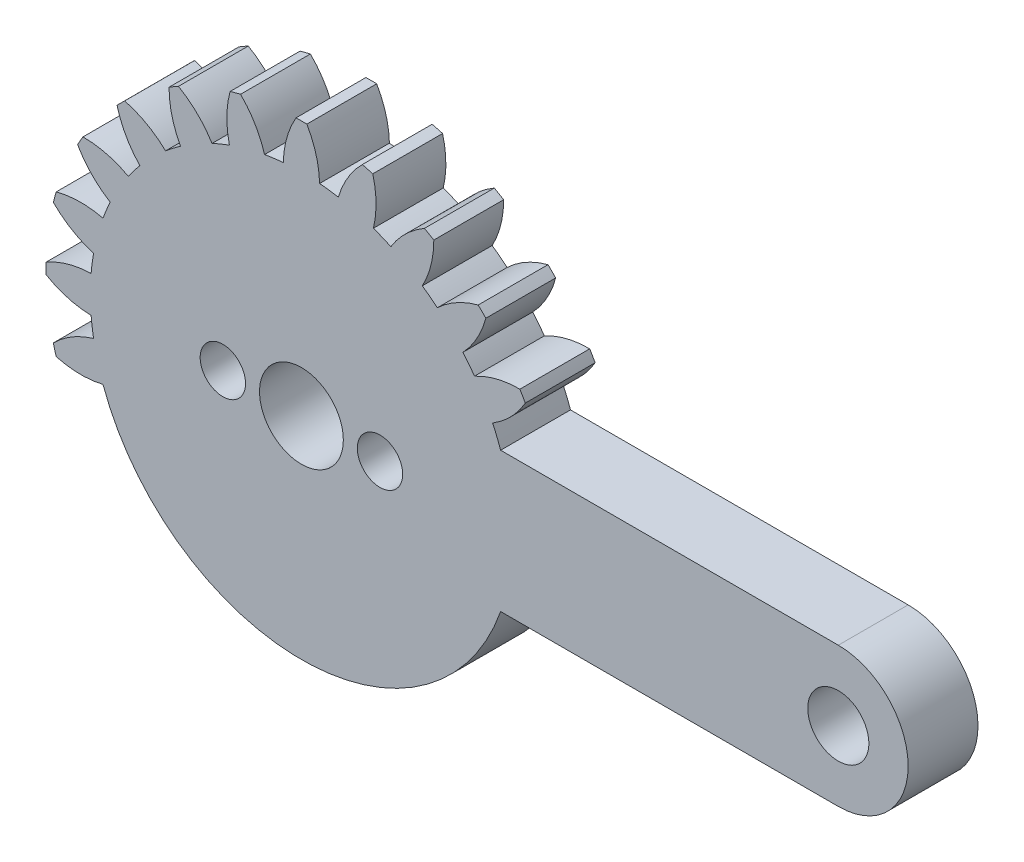
from build123d import *

# Parameters (mm, degrees)
ESQUISSE1_R                  = 1.75
BOSS_EXTRU_1_DEPTH           = 2
ESQUISSE2_R                  = 1.3
ESQUISSE2_R_2                = 2.4
ENL_V_MAT_EXTRU_1_DEPTH      = 1
ENL_V_MAT_EXTRU_1_DEPTH_BACK = 5


with BuildPart() as part:
    # Esquisse1 → Boss.-Extru.1 (new body, symmetric)
    with BuildSketch(Plane.XY):
        with BuildLine():
            ThreePointArc((30.75, -4), (34.75, 0), (30.75, 4))
            Line((30.75, 4), (11.409123542, 4))
            ThreePointArc((11.409123542, 4), (11.194344337, 4.566700654), (10.951436862, 5.12192646))
            ThreePointArc((10.951436862, 5.12192646), (12.008090957, 5.965388247), (12.82210701, 7.044889767))
            ThreePointArc((12.82210701, 7.044889767), (12.669951657, 7.315), (12.51210701, 7.581825517))
            ThreePointArc((12.51210701, 7.581825517), (11.170223244, 7.416617696), (9.911436862, 6.9232593))
            ThreePointArc((9.911436862, 6.9232593), (9.591641884, 7.359925677), (9.252623584, 7.781841479))
            ThreePointArc((9.252623584, 7.781841479), (10.05496909, 8.870045207), (10.561852666, 10.123446462))
            ThreePointArc((10.561852666, 10.123446462), (10.344972209, 10.344972209), (10.123446462, 10.561852666))
            ThreePointArc((10.123446462, 10.561852666), (8.870045207, 10.05496909), (7.781841479, 9.252623584))
            ThreePointArc((7.781841479, 9.252623584), (7.359925677, 9.591641884), (6.9232593, 9.911436862))
            ThreePointArc((6.9232593, 9.911436862), (7.416617696, 11.170223244), (7.581825517, 12.51210701))
            ThreePointArc((7.581825517, 12.51210701), (7.315, 12.669951657), (7.044889767, 12.82210701))
            ThreePointArc((7.044889767, 12.82210701), (5.965388247, 12.008090957), (5.12192646, 10.951436862))
            ThreePointArc((5.12192646, 10.951436862), (4.626642697, 11.169703548), (4.122086336, 11.365584201))
            ThreePointArc((4.122086336, 11.365584201), (4.272836063, 12.709169027), (4.085109489, 14.048088143))
            ThreePointArc((4.085109489, 14.048088143), (3.78652263, 14.131494839), (3.486235477, 14.208555951))
            ThreePointArc((3.486235477, 14.208555951), (2.654199937, 13.14288127), (2.112960617, 11.903927815))
            ThreePointArc((2.112960617, 11.903927815), (1.578061664, 11.986568374), (1.04, 12.04518576))
            ThreePointArc((1.04, 12.04518576), (0.837867713, 13.382005944), (0.31, 14.626715284))
            ThreePointArc((0.31, 14.626715284), (0, 14.63), (-0.31, 14.626715284))
            ThreePointArc((-0.31, 14.626715284), (-0.837867713, 13.382005944), (-1.04, 12.04518576))
            ThreePointArc((-1.04, 12.04518576), (-1.578061664, 11.986568374), (-2.112960617, 11.903927815))
            ThreePointArc((-2.112960617, 11.903927815), (-2.654199937, 13.14288127), (-3.486235477, 14.208555951))
            ThreePointArc((-3.486235477, 14.208555951), (-3.78652263, 14.131494839), (-4.085109489, 14.048088143))
            ThreePointArc((-4.085109489, 14.048088143), (-4.272836063, 12.709169027), (-4.122086336, 11.365584201))
            ThreePointArc((-4.122086336, 11.365584201), (-4.626642697, 11.169703548), (-5.12192646, 10.951436862))
            ThreePointArc((-5.12192646, 10.951436862), (-5.965388247, 12.008090957), (-7.044889767, 12.82210701))
            ThreePointArc((-7.044889767, 12.82210701), (-7.315, 12.669951657), (-7.581825517, 12.51210701))
            ThreePointArc((-7.581825517, 12.51210701), (-7.416617696, 11.170223244), (-6.9232593, 9.911436862))
            ThreePointArc((-6.9232593, 9.911436862), (-7.359925677, 9.591641884), (-7.781841479, 9.252623584))
            ThreePointArc((-7.781841479, 9.252623584), (-8.870045207, 10.05496909), (-10.123446462, 10.561852666))
            ThreePointArc((-10.123446462, 10.561852666), (-10.344972209, 10.344972209), (-10.561852666, 10.123446462))
            ThreePointArc((-10.561852666, 10.123446462), (-10.05496909, 8.870045207), (-9.252623584, 7.781841479))
            ThreePointArc((-9.252623584, 7.781841479), (-9.591641884, 7.359925677), (-9.911436862, 6.9232593))
            ThreePointArc((-9.911436862, 6.9232593), (-11.170223244, 7.416617696), (-12.51210701, 7.581825517))
            ThreePointArc((-12.51210701, 7.581825517), (-12.669951657, 7.315), (-12.82210701, 7.044889767))
            ThreePointArc((-12.82210701, 7.044889767), (-12.008090957, 5.965388247), (-10.951436862, 5.12192646))
            ThreePointArc((-10.951436862, 5.12192646), (-11.169703548, 4.626642697), (-11.365584201, 4.122086336))
            ThreePointArc((-11.365584201, 4.122086336), (-12.709169027, 4.272836063), (-14.048088143, 4.085109489))
            ThreePointArc((-14.048088143, 4.085109489), (-14.131494839, 3.78652263), (-14.208555951, 3.486235477))
            ThreePointArc((-14.208555951, 3.486235477), (-13.14288127, 2.654199937), (-11.903927815, 2.112960617))
            ThreePointArc((-11.903927815, 2.112960617), (-11.986568374, 1.578061664), (-12.04518576, 1.04))
            ThreePointArc((-12.04518576, 1.04), (-13.382005944, 0.837867713), (-14.626715284, 0.31))
            ThreePointArc((-14.626715284, 0.31), (-14.63, 0), (-14.626715284, -0.31))
            ThreePointArc((-14.626715284, -0.31), (-13.382005944, -0.837867713), (-12.04518576, -1.04))
            ThreePointArc((-12.04518576, -1.04), (-11.986568374, -1.578061664), (-11.903927815, -2.112960617))
            ThreePointArc((-11.903927815, -2.112960617), (-13.14288127, -2.654199937), (-14.208555951, -3.486235477))
            ThreePointArc((-14.208555951, -3.486235477), (-14.131494839, -3.78652263), (-14.048088143, -4.085109489))
            ThreePointArc((-14.048088143, -4.085109489), (-12.709169027, -4.272836063), (-11.365584201, -4.122086336))
            ThreePointArc((-11.365584201, -4.122086336), (0.064808849, -12.089826294), (11.409123542, -4))
            Line((11.409123542, -4), (30.75, -4))
        make_face()
        with Locations((30.75, 0)):
            Circle(ESQUISSE1_R, mode=Mode.SUBTRACT)
        Circle(ESQUISSE1_R, mode=Mode.SUBTRACT)
    extrude(amount=BOSS_EXTRU_1_DEPTH, both=True)

    # Esquisse2 → Enlèv. mat.-Extru.1 (cut, two sides)
    with BuildSketch(Plane.XY.offset(2)) as enl_v_mat_extru_1_sk:
        with Locations((4.5, 0)):
            Circle(ESQUISSE2_R)
        with Locations((-4.5, 0)):
            Circle(ESQUISSE2_R)
        Circle(ESQUISSE2_R_2)
    extrude(amount=ENL_V_MAT_EXTRU_1_DEPTH, mode=Mode.SUBTRACT)
    extrude(enl_v_mat_extru_1_sk.sketch, amount=-ENL_V_MAT_EXTRU_1_DEPTH_BACK, mode=Mode.SUBTRACT)


solid = part.part
